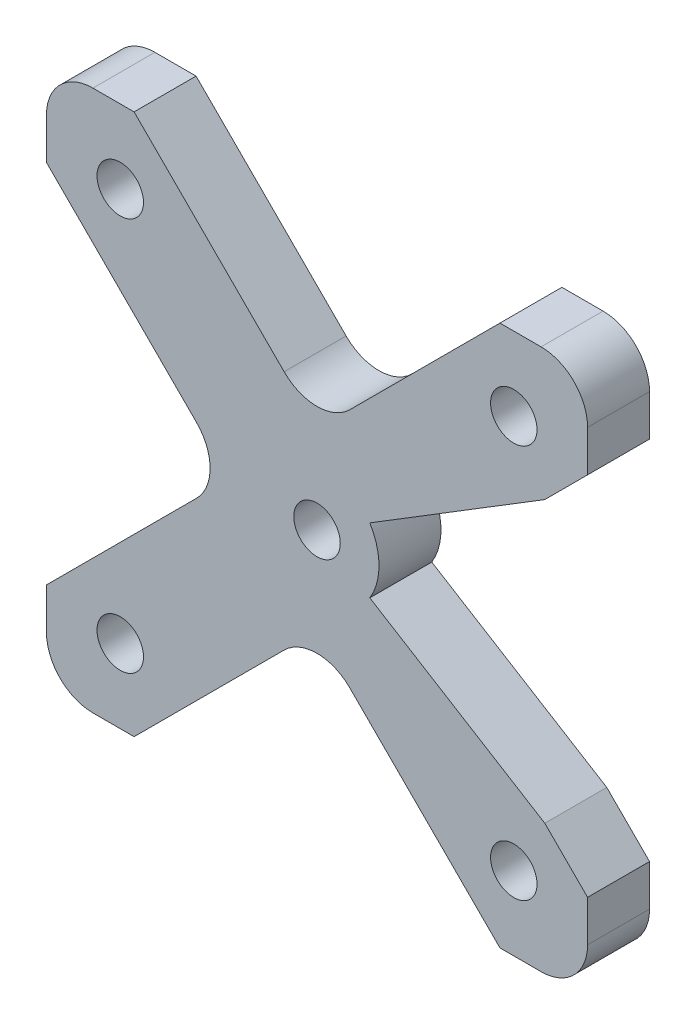
from build123d import *

# Parameters (mm, degrees)
SKETCH1_W           = 34.925
SKETCH1_H           = 34.925
SKETCH1_R           = 1.5
BOSS_EXTRUDE1_DEPTH = 4
CUT_EXTRUDE1_DEPTH  = 5.08
FILLET1_R           = 3
CUT_EXTRUDE2_DEPTH  = 5.08


with BuildPart() as part:
    # Sketch1 → Boss-Extrude1 (new body)
    with BuildSketch(Plane.XY):
        Rectangle(SKETCH1_W, SKETCH1_H)
        with Locations((-12.7, 12.7)):
            Circle(SKETCH1_R, mode=Mode.SUBTRACT)
        with Locations((12.7, 12.7)):
            Circle(SKETCH1_R, mode=Mode.SUBTRACT)
        with Locations((-12.7, -12.7)):
            Circle(SKETCH1_R, mode=Mode.SUBTRACT)
        with Locations((12.7, -12.7)):
            Circle(SKETCH1_R, mode=Mode.SUBTRACT)
        Circle(SKETCH1_R, mode=Mode.SUBTRACT)
    extrude(amount=BOSS_EXTRUDE1_DEPTH)

    # Sketch2 → Cut-Extrude1 (cut)
    with BuildSketch(Plane.XY.offset(4)):
        Polygon((-5.656854249, 0), (-17.4625, 11.805645751), (-17.4625, -11.805645751), align=None)
        Polygon((-11.805645751, 17.4625), (0, 5.656854249), (11.805645751, 17.4625), align=None)
        Polygon((17.4625, 11.805645751), (5.656854249, 0), (17.4625, -11.805645751), align=None)
        Polygon((11.805645751, -17.4625), (0, -5.656854249), (-11.805645751, -17.4625), align=None)
    extrude(amount=-CUT_EXTRUDE1_DEPTH, mode=Mode.SUBTRACT)

    # Fillet1
    fillet1_edges = [part.edges().sort_by_distance(p)[0] for p in [
        (-17.4625, 17.4625, 2),
        (17.4625, 17.4625, 2),
        (17.4625, -17.4625, 2),
        (-17.4625, -17.4625, 2),
        (5.656854249, 0, 2),
        (0, 5.656854249, 2),
        (0, -5.656854249, 2),
        (-5.656854249, 0, 2),
    ]]
    fillet(fillet1_edges, radius=FILLET1_R)

    # Sketch3 → Cut-Extrude2 (cut)
    with BuildSketch(Plane(origin=(0, 0, 0), x_dir=(-1, 0, 0), z_dir=(0, 0, -1))):
        with BuildLine():
            Line((-14.7, -9.043145751), (-3.406944413, -2.095884006))
            ThreePointArc((-3.406944413, -2.095884006), (-4, 0), (-3.406944413, 2.095884006))
            Line((-3.406944413, 2.095884006), (-14.7, 9.043145751))
            Line((-14.7, 9.043145751), (-7.778174593, 2.121320344))
            ThreePointArc((-7.778174593, 2.121320344), (-6.899494937, 0), (-7.778174593, -2.121320344))
            Line((-7.778174593, -2.121320344), (-14.7, -9.043145751))
        make_face()
    extrude(amount=-CUT_EXTRUDE2_DEPTH, mode=Mode.SUBTRACT)


solid = part.part
